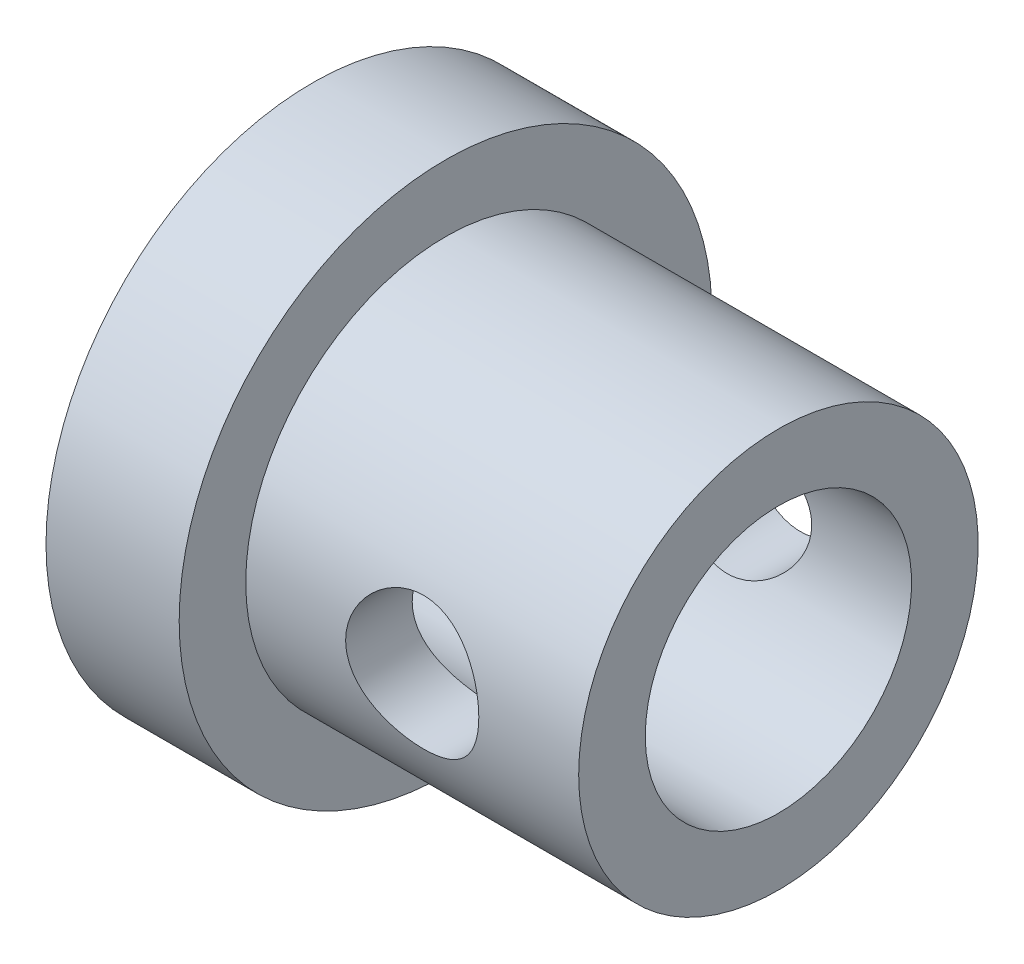
from build123d import *

# Parameters (mm, degrees)
SKETCH3_R          = 2
CUT_EXTRUDE1_DEPTH = 8
SKETCH4_R          = 1
CUT_EXTRUDE2_DEPTH = 5


with BuildPart() as part:
    # Sketch2 → Revolve1 (revolve)
    with BuildSketch(Plane.XY):
        Polygon((0, 0), (7, 0), (7, 3), (2, 3), (2, 4), (0, 4), align=None)
    revolve(axis=Axis((0, 0, 0), (1, 0, 0)))

    # Sketch3 → Cut-Extrude1 (cut, through all)
    with BuildSketch(Plane.ZY):
        Circle(SKETCH3_R)
    extrude(amount=-CUT_EXTRUDE1_DEPTH, mode=Mode.SUBTRACT)

    # Sketch4 → Cut-Extrude2 (cut, symmetric)
    with BuildSketch(Plane.XY):
        with Locations((4.5, 0)):
            Circle(SKETCH4_R)
    extrude(amount=CUT_EXTRUDE2_DEPTH, both=True, mode=Mode.SUBTRACT)


solid = part.part
